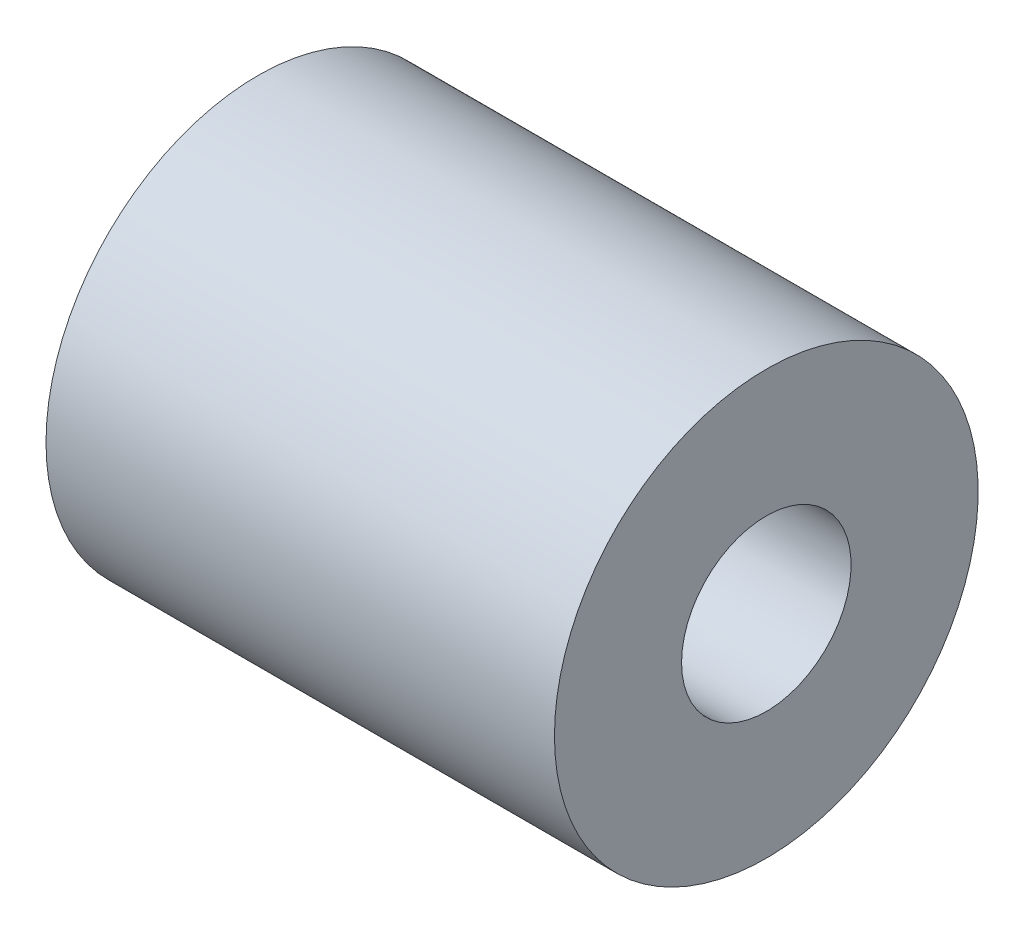
from build123d import *


with BuildPart() as part:
    # Skizze1 → Rotation1 (revolve)
    with BuildSketch(Plane.XY):
        Polygon((-6.925, 1), (-6, 1.925), (-6, 2.5), (0, 2.5), (0, 1), align=None)
    revolve(axis=Axis((-6.460075315, 0, 0), (1, 0, 0)))


solid = part.part
